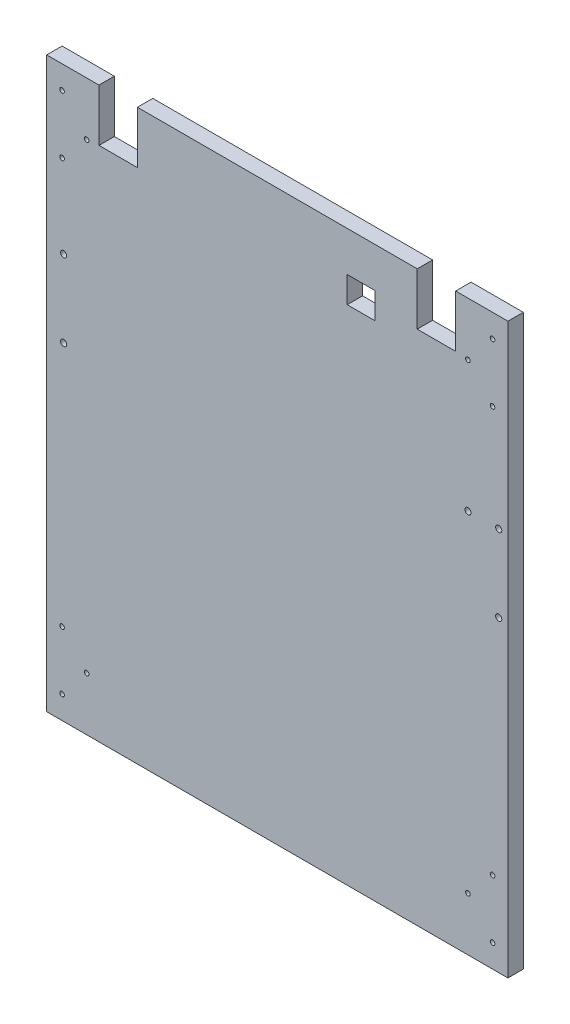
from build123d import *

# Parameters (mm, degrees)
SKETCH_1_W          = 300
SKETCH_1_H          = 370
EXTRUDE_1_DEPTH     = 10
SKETCH_2_R          = 1.5
SKETCH_2_R_2        = 2
SKETCH_2_W          = 25
SKETCH_2_H          = 34
CUT_EXTRUDE_1_DEPTH = 10


with BuildPart() as part:
    # 草图1 → 凸台-拉伸1 (new body)
    with BuildSketch(Plane.XY):
        with Locations((113.99815703, 205.554685433)):
            Rectangle(SKETCH_1_W, SKETCH_1_H)
    extrude(amount=EXTRUDE_1_DEPTH)

    # 草图2 → 切除-拉伸1 (cut)
    with BuildSketch(Plane.XY.offset(10)):
        with Locations((253.99815703, 375.554685433)):
            Circle(SKETCH_2_R)
        with Locations((253.99815703, 337.554685433)):
            Circle(SKETCH_2_R)
        with Locations((-26.00184297, 337.554685433)):
            Circle(SKETCH_2_R)
        with Locations((-26.00184297, 375.554685433)):
            Circle(SKETCH_2_R)
        with Locations((-26.00184297, 35.554685433)):
            Circle(SKETCH_2_R)
        with Locations((-26.00184297, 73.554685433)):
            Circle(SKETCH_2_R)
        with Locations((253.99815703, 73.554685433)):
            Circle(SKETCH_2_R)
        with Locations((253.99815703, 35.554685433)):
            Circle(SKETCH_2_R)
        with Locations((237.99815703, 355.804685433)):
            Circle(SKETCH_2_R)
        with Locations((-10.00184297, 355.804685433)):
            Circle(SKETCH_2_R)
        with Locations((-10.00184297, 55.304685433)):
            Circle(SKETCH_2_R)
        with Locations((237.99815703, 55.304685433)):
            Circle(SKETCH_2_R)
        with Locations((237.99815703, 270.554685433)):
            Circle(SKETCH_2_R_2)
        with Locations((257.99815703, 270.554685433)):
            Circle(SKETCH_2_R_2)
        with Locations((257.99815703, 220.554685433)):
            Circle(SKETCH_2_R_2)
        with Locations((-24.980137122, 233.80801348)):
            Circle(SKETCH_2_R_2)
        with Locations((-24.980137122, 283.80801348)):
            Circle(SKETCH_2_R_2)
        with Locations((217.49815703, 373.554685433)):
            Rectangle(SKETCH_2_W, SKETCH_2_H)
        with Locations((10.49815703, 373.554685433)):
            Rectangle(SKETCH_2_W, SKETCH_2_H)
        Polygon((159.455584524, 355.554685433), (159.455584524, 364.554685433), (177.455584524, 364.554685433), (177.455584524, 356.554685433), (177.455584524, 347.554685433), (159.455584524, 347.554685433), align=None)
    extrude(amount=-CUT_EXTRUDE_1_DEPTH, mode=Mode.SUBTRACT)


solid = part.part
